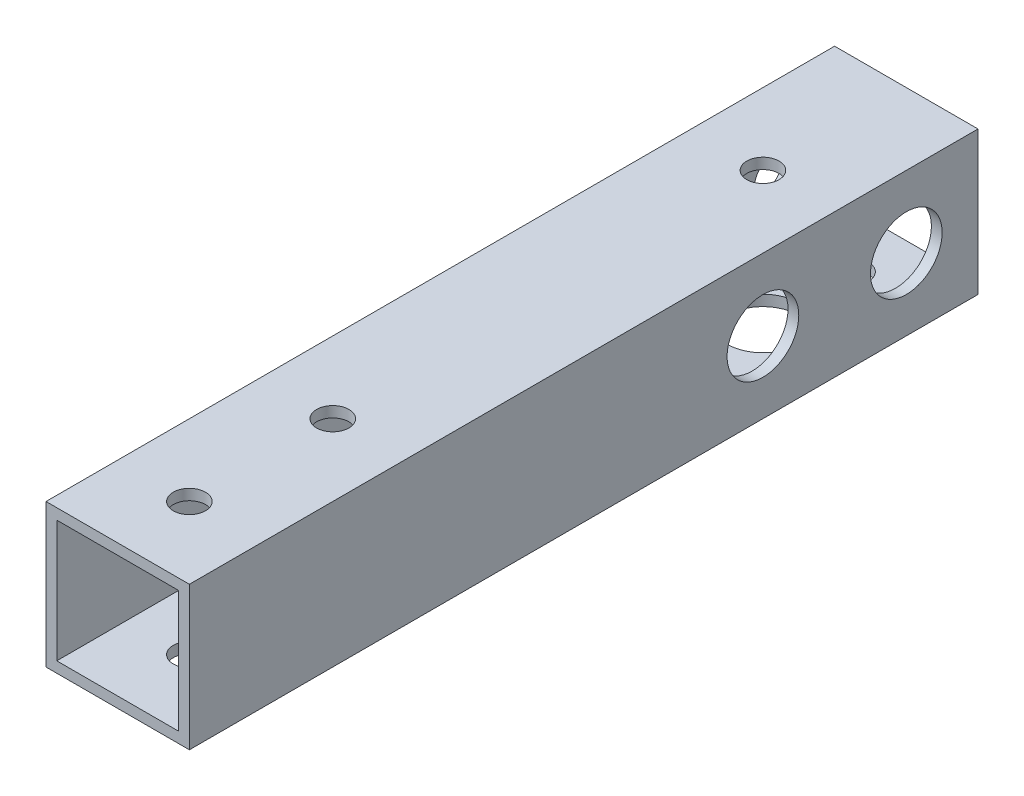
from build123d import *

# Parameters (mm, degrees)
SKETCH_1_W          = 20
SKETCH_1_H          = 20
SKETCH_1_W_2        = 17
SKETCH_1_H_2        = 17
EXTRUDE_1_DEPTH     = 110
SKETCH_2_R          = 2.7
CUT_EXTRUDE_1_DEPTH = 25
SKETCH_3_R          = 2.25
CUT_EXTRUDE_2_DEPTH = 20
SKETCH_4_R          = 2.25
CUT_EXTRUDE_3_DEPTH = 5
SKETCH_5_R          = 5
CUT_EXTRUDE_4_DEPTH = 10
SKETCH_6_R          = 5
CUT_EXTRUDE_5_DEPTH = 10


with BuildPart() as part:
    # ｽｹｯﾁ1 → ﾎﾞｽ - 押し出し1 (new body)
    with BuildSketch(Plane.XY):
        Rectangle(SKETCH_1_W, SKETCH_1_H)
        Rectangle(SKETCH_1_W_2, SKETCH_1_H_2, mode=Mode.SUBTRACT)
    extrude(amount=EXTRUDE_1_DEPTH)

    # ｽｹｯﾁ2 → ｶｯﾄ - 押し出し1 (cut)
    with BuildSketch(Plane(origin=(10, 0, 0), x_dir=(0, 0, -1), z_dir=(1, 0, 0))):
        with Locations((-30, 0)):
            Circle(SKETCH_2_R)
        with Locations((-10, 0)):
            Circle(SKETCH_2_R)
    extrude(amount=-CUT_EXTRUDE_1_DEPTH, mode=Mode.SUBTRACT)

    # ｽｹｯﾁ3 → ｶｯﾄ - 押し出し2 (cut)
    with BuildSketch(Plane(origin=(0, 10, 0), x_dir=(1, 0, 0), z_dir=(0, 1, 0))):
        with Locations((0, -100)):
            Circle(SKETCH_3_R)
        with Locations((0, -80)):
            Circle(SKETCH_3_R)
        with Locations((0, -20)):
            Circle(SKETCH_3_R)
    extrude(amount=-CUT_EXTRUDE_2_DEPTH, mode=Mode.SUBTRACT)

    # ｽｹｯﾁ4 → ｶｯﾄ - 押し出し3 (cut)
    with BuildSketch(Plane(origin=(0, -10, 0), x_dir=(-1, 0, 0), z_dir=(0, -1, 0))):
        with Locations((0, -7.5)):
            Circle(SKETCH_4_R)
    extrude(amount=-CUT_EXTRUDE_3_DEPTH, mode=Mode.SUBTRACT)

    # ｽｹｯﾁ5 → ｶｯﾄ - 押し出し4 (cut)
    with BuildSketch(Plane(origin=(0, -10, 0), x_dir=(-1, 0, 0), z_dir=(0, -1, 0))):
        with Locations((0, -20)):
            Circle(SKETCH_5_R)
    extrude(amount=-CUT_EXTRUDE_4_DEPTH, mode=Mode.SUBTRACT)

    # ｽｹｯﾁ6 → ｶｯﾄ - 押し出し5 (cut)
    with BuildSketch(Plane(origin=(10, 0, 0), x_dir=(0, 0, -1), z_dir=(1, 0, 0))):
        with Locations((-10, 0)):
            Circle(SKETCH_6_R)
        with Locations((-30, 0)):
            Circle(SKETCH_6_R)
    extrude(amount=-CUT_EXTRUDE_5_DEPTH, mode=Mode.SUBTRACT)


solid = part.part
